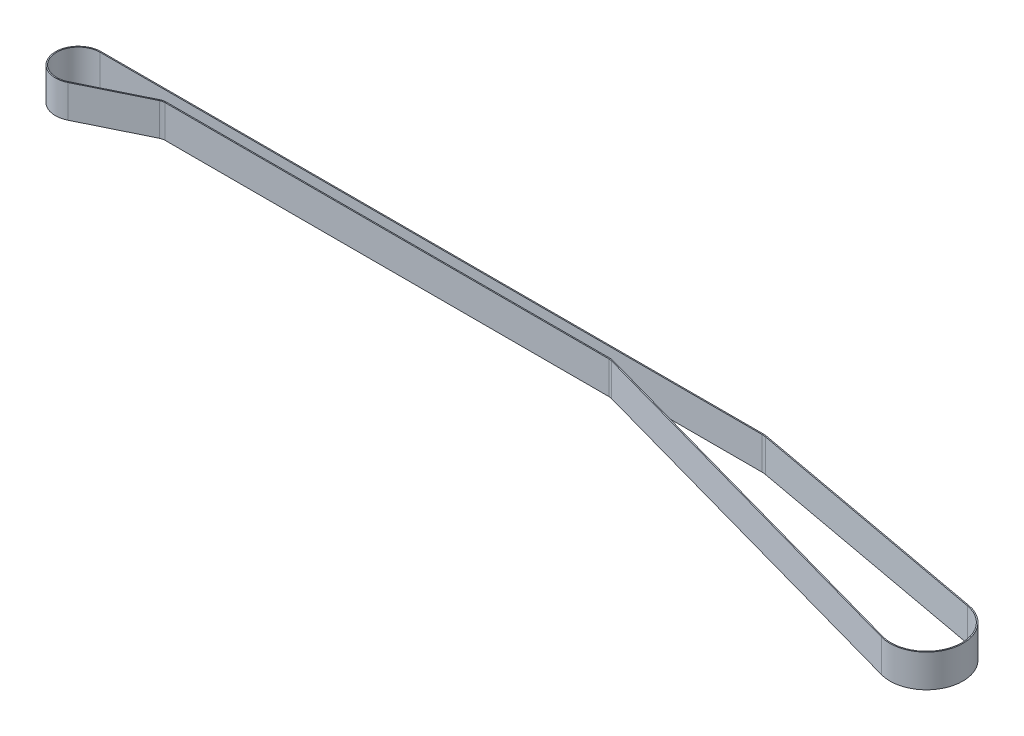
from build123d import *

# Parameters (mm, degrees)
BOSS_EXTRUDE1_DEPTH = 15


with BuildPart() as part:
    # Sketch1 → Boss-Extrude1 (new body)
    with BuildSketch(Plane(origin=(0, 0, 0), x_dir=(1, 0, 0), z_dir=(0, 1, 0))):
        with BuildLine():
            ThreePointArc((-659.025122037, 412.448905192), (-659.689338477, 412.586057046), (-660.366005428, 412.632056457))
            Line((-660.366005428, 412.632056457), (-864.195118688, 412.632056457))
            ThreePointArc((-864.195118688, 412.632056457), (-865.324084301, 412.502932831), (-866.39473946, 412.122231116))
            Line((-866.39473946, 412.122231116), (-894.575915261, 398.316999834))
            ThreePointArc((-894.575915261, 398.316999834), (-909.423967253, 405.375573292), (-899.195089964, 418.246366617))
            Line((-899.195089964, 418.246366617), (-595.213920413, 418.24431837))
            ThreePointArc((-595.213920413, 418.24431837), (-594.262691586, 418.201142157), (-593.319285704, 418.071968602))
            Line((-593.319285704, 418.071968602), (-479.651763212, 397.219361415))
            ThreePointArc((-479.651763212, 397.219361415), (-466.351873551, 376.983335948), (-487.166106805, 364.607897137))
            Line((-487.166106805, 364.607897137), (-659.025122037, 412.448905192))
        make_face()
        with BuildLine():
            Line((-658.891051676, 412.930525483), (-487.045817139, 365.093353609))
            ThreePointArc((-487.045817139, 365.093353609), (-466.835293219, 377.176572267), (-479.911630321, 396.759188493))
            Line((-479.911630321, 396.759188493), (-593.409278239, 417.581166717))
            ThreePointArc((-593.409278239, 417.581166717), (-594.307856674, 417.704206285), (-595.213886711, 417.745334257))
            Line((-595.213886711, 417.745334257), (-899.19505992, 417.746358527))
            ThreePointArc((-899.19505992, 417.746358527), (-908.936889556, 405.488468327), (-894.795900883, 398.766001802))
            Line((-894.795900883, 398.766001802), (-866.61470183, 412.571185618))
            ThreePointArc((-866.61470183, 412.571185618), (-865.436984962, 412.989954476), (-864.195127301, 413.131989419))
            Line((-864.195127301, 413.131989419), (-660.366014041, 413.131989419))
            ThreePointArc((-660.366014041, 413.131989419), (-659.621685121, 413.081391266), (-658.891051676, 412.930525483))
        make_face(mode=Mode.SUBTRACT)
    extrude(amount=BOSS_EXTRUDE1_DEPTH)


solid = part.part
